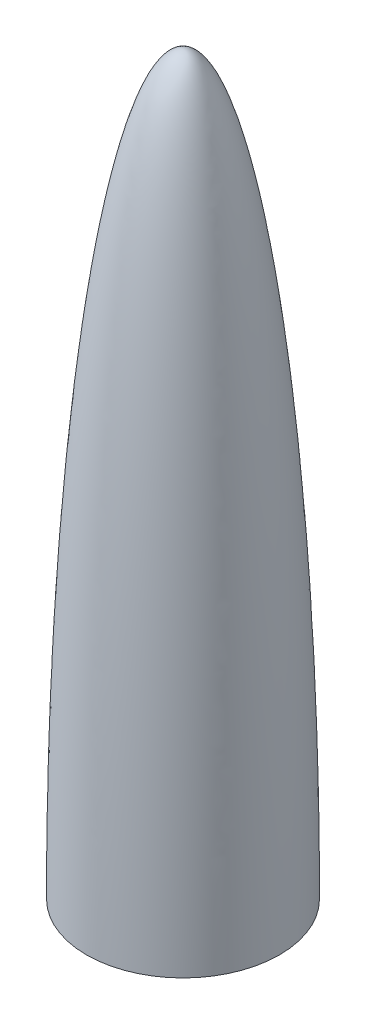
from build123d import *


with BuildPart() as part:
    # Croquis1 → Revolución1 (revolve)
    with BuildSketch(Plane.XY):
        with BuildLine():
            add(Edge.make_bspline(
                [(38.8, 0), (38.8, 9.96011632), (38.67145018, 29.935177825), (38.094859343, 59.565075974), (37.140028383, 88.632045999), (35.375188767, 126.244633967), (32.277379041, 170.438391327), (27.275926329, 216.905551348), (22.200716477, 248.658065048), (17.719355496, 269.135703201), (14.18482477, 281.879924995), (10.521209373, 291.870823581), (7.411748453, 297.79544932), (4.959920866, 301.03094325), (3.182750841, 302.695869879), (1.509516927, 303.616383263), (0.523002368, 303.8), (0, 303.8)],
                knots=[-1.570796327, -1.570796327, -1.570796327, -1.570796327, -1.472621556, -1.374446786, -1.276272016, -1.178097245, -0.981747704, -0.785398163, -0.589048623, -0.490873852, -0.392699082, -0.294524311, -0.196349541, -0.147262156, -0.09817477, -0.049087385, 0, 0, 0, 0], degree=3))
            Line((0, 303.8), (0, 305))
            add(Edge.make_bspline(
                [(40, 0), (40, 305), (0, 305)],
                knots=[4.71238898, 4.71238898, 4.71238898, 6.283185307, 6.283185307, 6.283185307], degree=2, weights=[1, 0.707106781, 1]))
            Line((40, 0), (38.8, 0))
        make_face()
    revolve(axis=Axis((0, 0, 0), (0, 1, 0)))


solid = part.part
